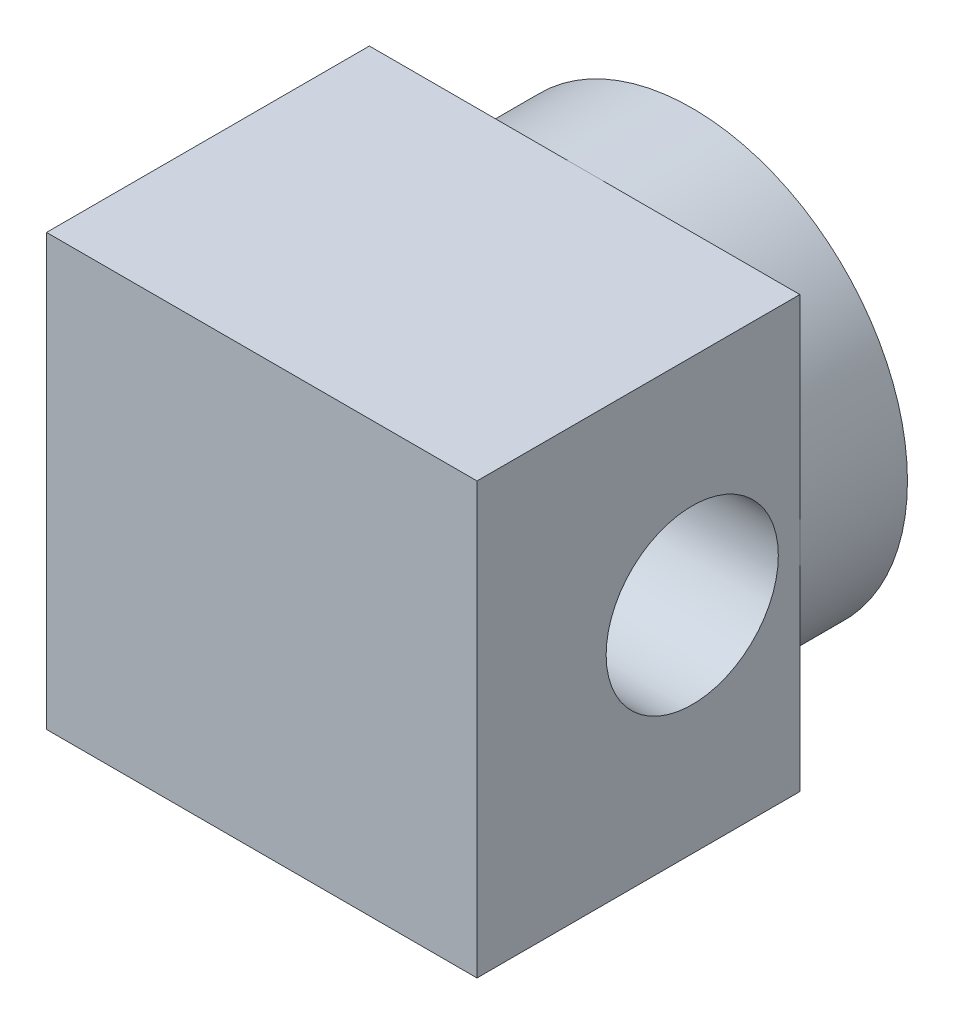
from build123d import *

# Parameters (mm, degrees)
SKETCH1_R           = 5
BOSS_EXTRUDE1_DEPTH = 10
SKETCH3_W           = 10
SKETCH3_H           = 10
BOSS_EXTRUDE2_DEPTH = 7.5
SKETCH2_R           = 2
CUT_EXTRUDE1_DEPTH  = 11


with BuildPart() as part:
    # Sketch1 → Boss-Extrude1 (new body)
    with BuildSketch(Plane.XY):
        Circle(SKETCH1_R)
    extrude(amount=BOSS_EXTRUDE1_DEPTH)

    # Sketch3 → Boss-Extrude2 (add)
    with BuildSketch(Plane.XY.offset(10)):
        Rectangle(SKETCH3_W, SKETCH3_H)
    extrude(amount=-BOSS_EXTRUDE2_DEPTH)

    # Sketch2 → Cut-Extrude1 (cut, through all)
    with BuildSketch(Plane(origin=(5, 0, 0), x_dir=(0, 0, -1), z_dir=(1, 0, 0))):
        with Locations((-5, 0)):
            Circle(SKETCH2_R)
    extrude(amount=-CUT_EXTRUDE1_DEPTH, mode=Mode.SUBTRACT)


solid = part.part
